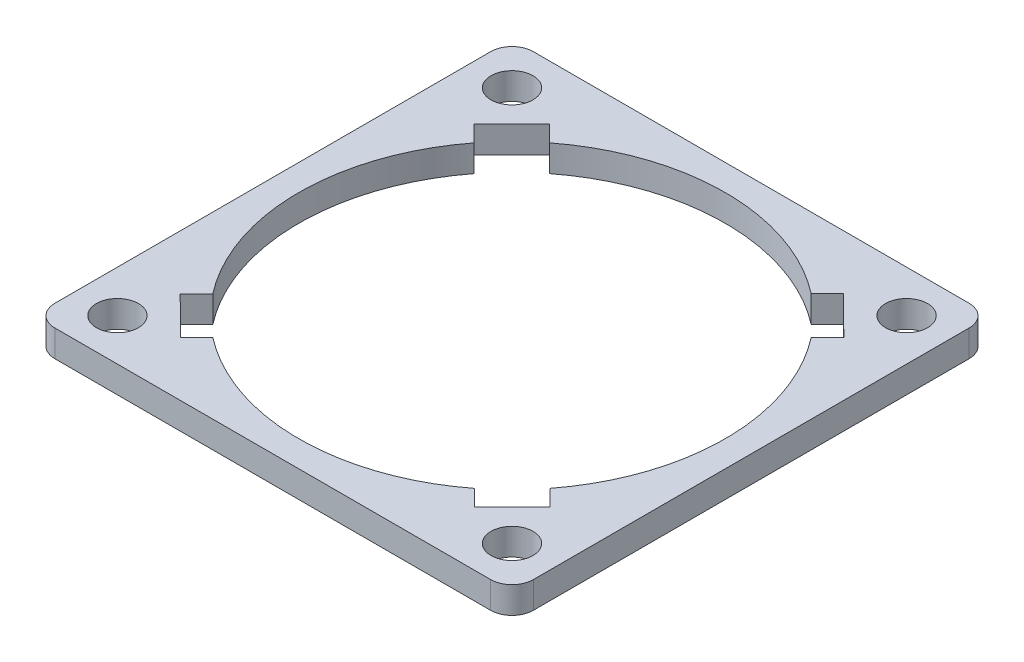
from build123d import *

# Parameters (mm, degrees)
SKETCH1_R           = 2.499995
BOSS_EXTRUDE1_DEPTH = 3.175


with BuildPart() as part:
    # Sketch1 → Boss-Extrude1 (new body)
    with BuildSketch(Plane(origin=(0, 0, 0), x_dir=(1, 0, 0), z_dir=(0, 1, 0))):
        with BuildLine():
            Line((-13.993314597, 28.4999938), (-25.9599938, 28.4999938))
            ThreePointArc((-25.9599938, 28.4999938), (-27.756045024, 27.756045024), (-28.4999938, 25.9599938))
            Line((-28.4999938, 25.9599938), (-28.4999938, 13.993314597))
            Line((-28.4999938, 13.993314597), (-28.4999938, -13.993314597))
            Line((-28.4999938, -13.993314597), (-28.4999938, -25.9599938))
            ThreePointArc((-28.4999938, -25.9599938), (-27.756045024, -27.756045024), (-25.9599938, -28.4999938))
            Line((-25.9599938, -28.4999938), (-13.993314597, -28.4999938))
            Line((-13.993314597, -28.4999938), (13.993314597, -28.4999938))
            Line((13.993314597, -28.4999938), (25.9599938, -28.4999938))
            ThreePointArc((25.9599938, -28.4999938), (27.756045024, -27.756045024), (28.4999938, -25.9599938))
            Line((28.4999938, -25.9599938), (28.4999938, -13.993314597))
            Line((28.4999938, -13.993314597), (28.4999938, 13.993314597))
            Line((28.4999938, 13.993314597), (28.4999938, 25.9599938))
            ThreePointArc((28.4999938, 25.9599938), (27.756045024, 27.756045024), (25.9599938, 28.4999938))
            Line((25.9599938, 28.4999938), (13.993314597, 28.4999938))
            Line((13.993314597, 28.4999938), (-13.993314597, 28.4999938))
        make_face()
        with Locations((-23.5000038, 23.5000038)):
            Circle(SKETCH1_R, mode=Mode.SUBTRACT)
        with Locations((23.5000038, 23.5000038)):
            Circle(SKETCH1_R, mode=Mode.SUBTRACT)
        with Locations((23.5000038, -23.5000038)):
            Circle(SKETCH1_R, mode=Mode.SUBTRACT)
        with Locations((-23.5000038, -23.5000038)):
            Circle(SKETCH1_R, mode=Mode.SUBTRACT)
        with BuildLine():
            Line((17.525786369, -21.990248683), (15.587608536, -20.05458701))
            ThreePointArc((15.587608536, -20.05458701), (0.016497958, -25.399994642), (-15.561543442, -20.074819195))
            Line((-15.561543442, -20.074819195), (-17.497205115, -22.012997028))
            Line((-17.497205115, -22.012997028), (-21.990248683, -17.525786369))
            Line((-21.990248683, -17.525786369), (-20.05458701, -15.587608536))
            ThreePointArc((-20.05458701, -15.587608536), (-25.399994642, -0.016497958), (-20.074819195, 15.561543442))
            Line((-20.074819195, 15.561543442), (-22.012997028, 17.497205115))
            Line((-22.012997028, 17.497205115), (-17.525786369, 21.990248683))
            Line((-17.525786369, 21.990248683), (-15.587608536, 20.05458701))
            ThreePointArc((-15.587608536, 20.05458701), (-0.016497958, 25.399994642), (15.561543442, 20.074819195))
            Line((15.561543442, 20.074819195), (17.497205115, 22.012997028))
            Line((17.497205115, 22.012997028), (21.990248683, 17.525786369))
            Line((21.990248683, 17.525786369), (20.05458701, 15.587608536))
            ThreePointArc((20.05458701, 15.587608536), (25.399994642, 0.016497958), (20.074819195, -15.561543442))
            Line((20.074819195, -15.561543442), (22.012997028, -17.497205115))
            Line((22.012997028, -17.497205115), (17.525786369, -21.990248683))
        make_face(mode=Mode.SUBTRACT)
    extrude(amount=BOSS_EXTRUDE1_DEPTH)


solid = part.part
